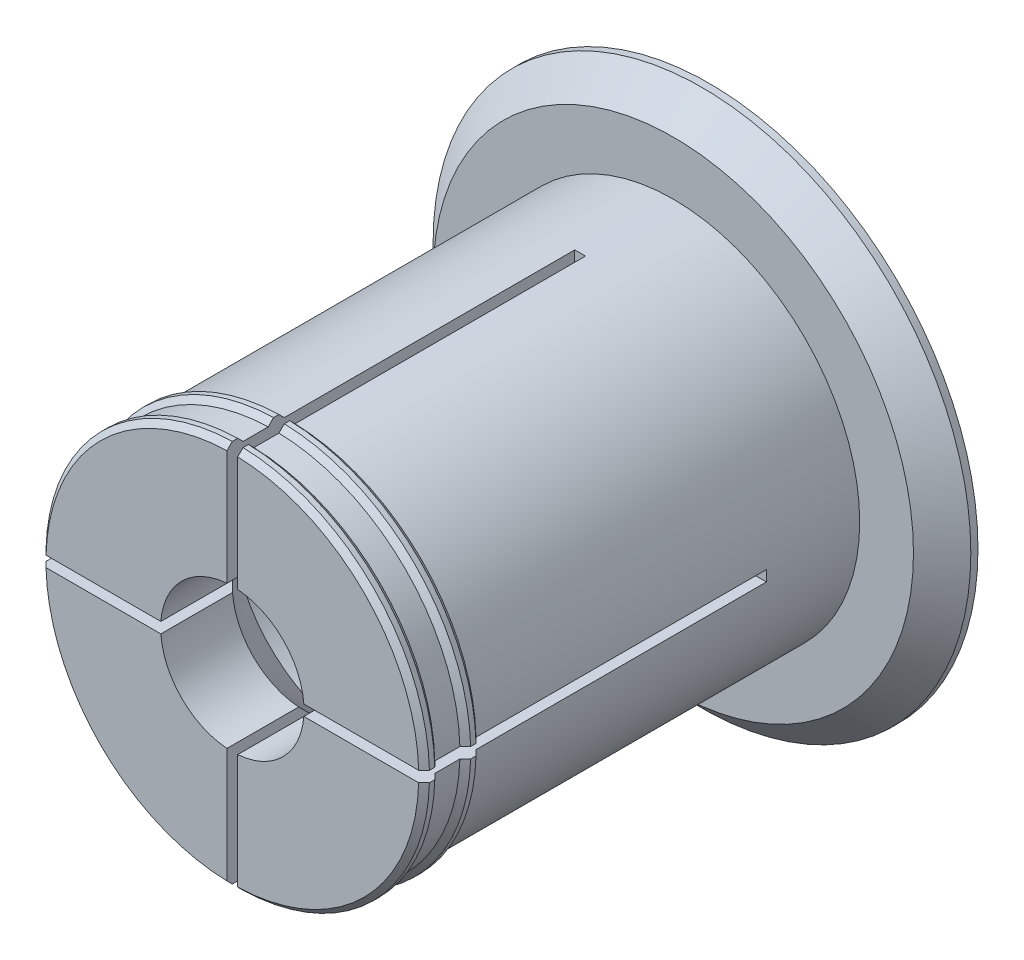
from build123d import *

# Parameters (mm, degrees)
AXLE_BASE_SKETCH_R        = 26
AXLE_DEPTH                = 61.5
GUARD_BASE_R              = 37.5
GUARD_DEPTH               = 5
INNER_AXLE_HOLE_BASE_R    = 10
INNER_AXLE_HOLE_DEPTH     = 67.5
BEND_START                = -48.5
BEND_ROOM_BASE_W          = 1.5
BEND_ROOM_BASE_H          = 75
BEND_ROOM_1_DEPTH         = 48.5
BEND_ROOM_2_COUNT         = 2
BEND_ROOM_2_ANGLE         = 90
EASY_REMOVAL_CHAMFER_SIZE = 4


with BuildPart() as part:
    # Axle base sketch → Axle (new body)
    with BuildSketch(Plane.XY):
        Circle(AXLE_BASE_SKETCH_R)
    extrude(amount=AXLE_DEPTH)

    # Guard base → Guard (add)
    with BuildSketch(Plane(origin=(0, 0, 0), x_dir=(-1, 0, 0), z_dir=(0, 0, -1))):
        Circle(GUARD_BASE_R)
    extrude(amount=GUARD_DEPTH)

    # Inner axle hole base → Inner axle hole (cut, through all)
    with BuildSketch(Plane.XY.offset(61.5)):
        Circle(INNER_AXLE_HOLE_BASE_R)
    extrude(amount=-INNER_AXLE_HOLE_DEPTH, mode=Mode.SUBTRACT)

    # Mate ring base → Mate rings (revolve)
    with BuildSketch(Plane(origin=(0, 0, 0), x_dir=(1, 0, 0), z_dir=(0, 1, 0))):
        Polygon((26, -61.5), (26.75, -60.75), (26.75, -60), (26, -59.25), align=None)
        Polygon((26, -55.75), (26.75, -55), (26.75, -54.25), (26, -53.5), align=None)
    revolve(axis=Axis((0, 0, 0), (0, 0, -1)))

    # Inner mass remove base → Inner mass remove (revolve, cut)
    with BuildSketch(Plane(origin=(0, 0, 0), x_dir=(0, 0, -1), z_dir=(1, 0, 0))):
        Polygon((-61.5, 0), (-43.5, -18), (-13, -18), (5, 0), align=None)
    revolve(axis=Axis((0, 0, 0), (0, 0, -1)), mode=Mode.SUBTRACT)

    # Bend room base → Bend room 1 (cut)
    with BuildSketch(Plane.XY.offset(61.5).offset(BEND_START)):
        Rectangle(BEND_ROOM_BASE_W, BEND_ROOM_BASE_H)
    bend_room_1 = extrude(amount=BEND_ROOM_1_DEPTH, mode=Mode.SUBTRACT)

    # Bend room 2: Bend room 1 ×2 about axis
    bend_room_2_axis = Axis((0, 0, 0), (0, 0, -1))
    for i in range(1, BEND_ROOM_2_COUNT):
        add(bend_room_1.rotate(bend_room_2_axis, i * BEND_ROOM_2_ANGLE / (BEND_ROOM_2_COUNT - 1)), mode=Mode.SUBTRACT)

    # Easy removal chamfer
    easy_removal_chamfer_edges = [part.edges().sort_by_distance(p)[0] for p in [
        (37.5, 0, 0),
    ]]
    chamfer(easy_removal_chamfer_edges, length=EASY_REMOVAL_CHAMFER_SIZE)


solid = part.part
